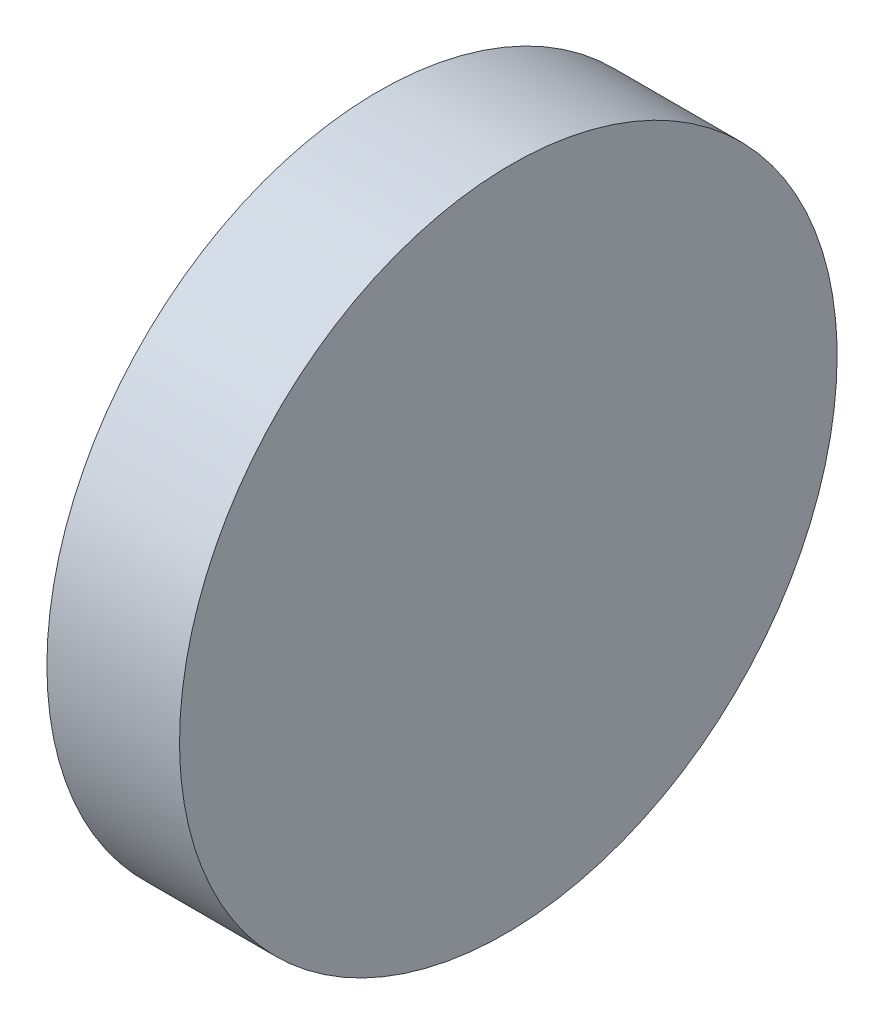
from build123d import *

# Parameters (mm, degrees)
EXTRUDE_1_DEPTH     = 25
CUT_EXTRUDE_2_DEPTH = 12.5


with BuildPart() as part:
    # 草图1 → 凸台-拉伸1 (new body)
    with BuildSketch(Plane(origin=(0, 0, 0), x_dir=(1, 0, 0), z_dir=(0, 1, 0))):
        Polygon((0, 12.5), (0, -12.5), (5, -12.5), (4.781828305, 12.5), align=None)
    extrude(amount=EXTRUDE_1_DEPTH)

    # 草图5 → 切除-拉伸2 (cut)
    with BuildSketch(Plane.ZY):
        with BuildLine():
            Line((-12.5, 25), (-12.5, 12.5))
            ThreePointArc((-12.5, 12.5), (-8.838834765, 21.338834765), (0, 25))
            Line((0, 25), (-12.5, 25))
        make_face()
        with BuildLine():
            Line((-12.5, 12.5), (-12.5, 0))
            Line((-12.5, 0), (-5.1e-08, 0))
            ThreePointArc((-5.1e-08, 0), (-8.838834783, 3.661165253), (-12.5, 12.5))
        make_face()
        with BuildLine():
            ThreePointArc((12.5, 12.5), (8.838834747, 3.661165217), (-5.1e-08, 0))
            Line((-5.1e-08, 0), (12.5, 0))
            Line((12.5, 0), (12.5, 12.5))
        make_face()
        with BuildLine():
            ThreePointArc((0, 25), (8.838834765, 21.338834765), (12.5, 12.5))
            Line((12.5, 12.5), (12.5, 25))
            Line((12.5, 25), (0, 25))
        make_face()
    extrude(amount=-CUT_EXTRUDE_2_DEPTH, mode=Mode.SUBTRACT)


solid = part.part
